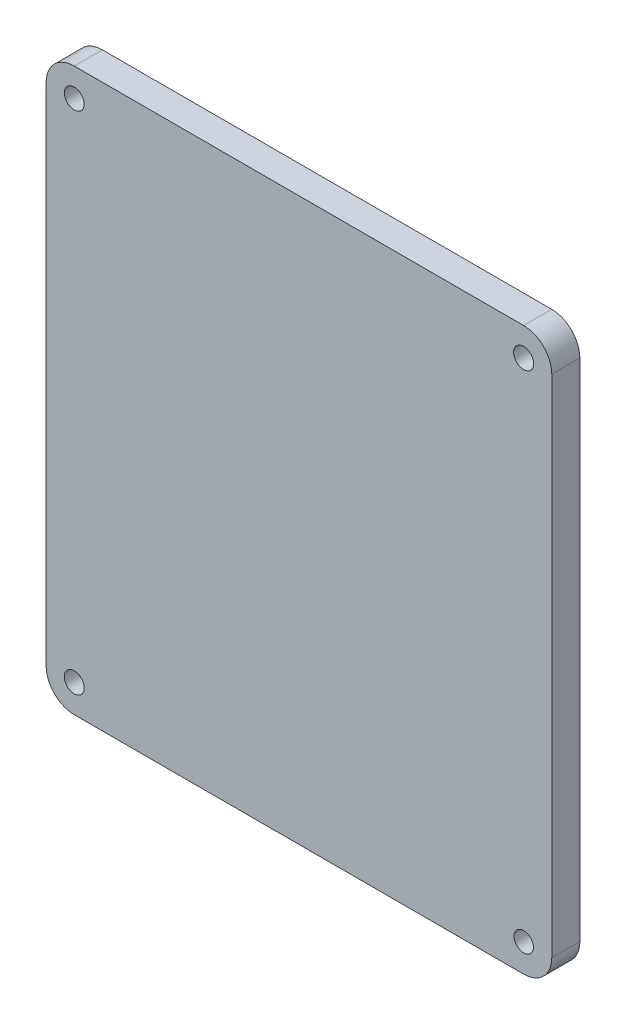
from build123d import *

# Parameters (mm, degrees)
BOSS_EXTRUDE1_DEPTH = 10
SKETCH3_R           = 3.557564602
SKETCH3_R_2         = 3.450101743
SKETCH3_R_3         = 3.575777986
SKETCH3_R_4         = 3.531796189
CUT_EXTRUDE3_DEPTH  = 10


with BuildPart() as part:
    # Sketch1 → Boss-Extrude1 (new body)
    with BuildSketch(Plane.XY):
        with BuildLine():
            Line((93.218232421, -42.83064586), (-66.781767579, -42.83064586))
            ThreePointArc((-66.781767579, -42.83064586), (-73.852835391, -39.901713672), (-76.781767579, -32.83064586))
            Line((-76.781767579, -32.83064586), (-76.781767579, 147.16935414))
            ThreePointArc((-76.781767579, 147.16935414), (-73.852835391, 154.240421952), (-66.781767579, 157.16935414))
            Line((-66.781767579, 157.16935414), (93.218232421, 157.16935414))
            ThreePointArc((93.218232421, 157.16935414), (100.289300233, 154.240421952), (103.218232421, 147.16935414))
            Line((103.218232421, 147.16935414), (103.218232421, -32.83064586))
            ThreePointArc((103.218232421, -32.83064586), (100.289300233, -39.901713672), (93.218232421, -42.83064586))
        make_face()
    extrude(amount=BOSS_EXTRUDE1_DEPTH)

    # Sketch3 → Cut-Extrude3 (cut)
    with BuildSketch(Plane.XY.offset(10)):
        with Locations((-66.781767579, -32.83064586)):
            Circle(SKETCH3_R)
        with Locations((93.218232421, -32.83064586)):
            Circle(SKETCH3_R_2)
        with Locations((93.218232421, 147.16935414)):
            Circle(SKETCH3_R_3)
        with Locations((-66.781767579, 147.16935414)):
            Circle(SKETCH3_R_4)
    extrude(amount=-CUT_EXTRUDE3_DEPTH, mode=Mode.SUBTRACT)


solid = part.part
